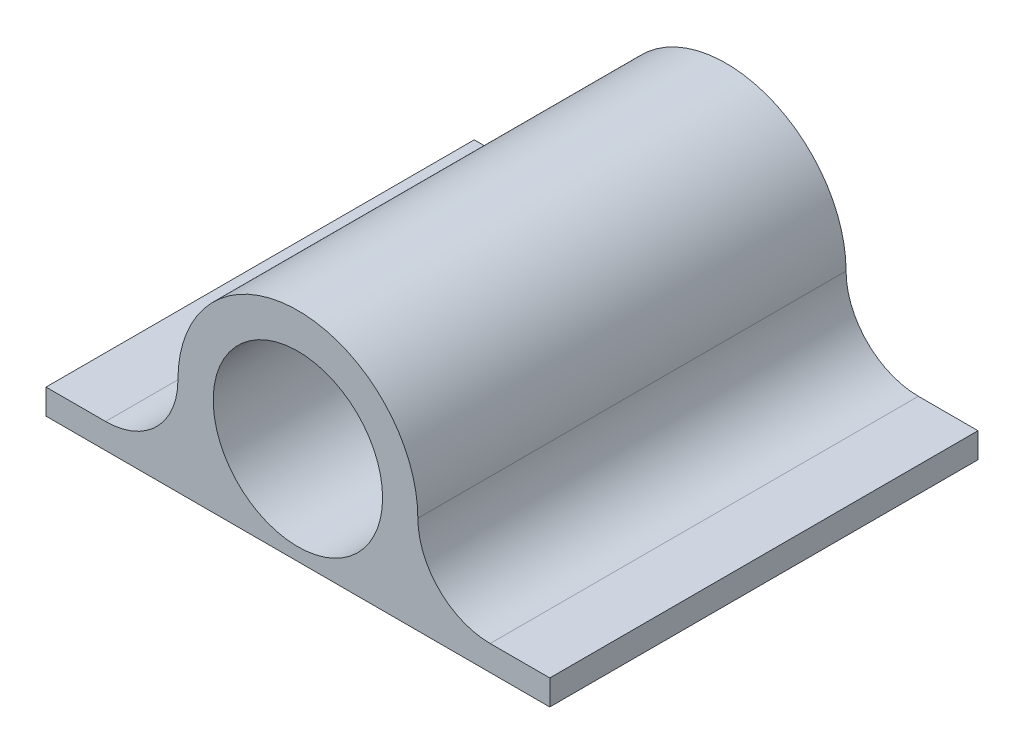
from build123d import *

# Parameters (mm, degrees)
SKETCH1_R           = 3.1115
BOSS_EXTRUDE1_DEPTH = 20.32
SKETCH2_R           = 1.905
BOSS_EXTRUDE2_DEPTH = 1.27
SKETCH3_R           = 4.27
CUT_EXTRUDE1_DEPTH  = 10.16


with BuildPart() as part:
    # Sketch1 → Boss-Extrude1 (new body)
    with BuildSketch(Plane.XY):
        with BuildLine():
            Line((-9.694539288, -3.646539288), (-12.7, -3.646539288))
            Line((-12.7, -3.646539288), (-12.7, -4.916539288))
            Line((-12.7, -4.916539288), (12.7, -4.916539288))
            Line((12.7, -4.916539288), (12.7, -3.646539288))
            Line((12.7, -3.646539288), (9.694539288, -3.646539288))
            ThreePointArc((9.694539288, -3.646539288), (7.11604663, -2.578492658), (6.048, 0))
            ThreePointArc((6.048, 0), (0, 6.048), (-6.048, 0))
            ThreePointArc((-6.048, 0), (-7.11604663, -2.578492658), (-9.694539288, -3.646539288))
        make_face()
        Circle(SKETCH1_R, mode=Mode.SUBTRACT)
    extrude(amount=BOSS_EXTRUDE1_DEPTH)

    # Sketch2 → Boss-Extrude2 (add)
    with BuildSketch(Plane(origin=(0, 0, 0), x_dir=(-1, 0, 0), z_dir=(0, 0, -1))):
        with BuildLine():
            Line((12.7, -4.916539288), (12.7, -3.646539288))
            Line((12.7, -3.646539288), (9.694539288, -3.646539288))
            ThreePointArc((9.694539288, -3.646539288), (7.11604663, -2.578492658), (6.048, 0))
            ThreePointArc((6.048, 0), (0, 6.048), (-6.048, 0))
            ThreePointArc((-6.048, 0), (-7.11604663, -2.578492658), (-9.694539288, -3.646539288))
            Line((-9.694539288, -3.646539288), (-12.7, -3.646539288))
            Line((-12.7, -3.646539288), (-12.7, -4.916539288))
            Line((-12.7, -4.916539288), (12.7, -4.916539288))
        make_face()
        Circle(SKETCH2_R, mode=Mode.SUBTRACT)
    extrude(amount=BOSS_EXTRUDE2_DEPTH)

    # Sketch3 → Cut-Extrude1 (cut)
    with BuildSketch(Plane.XY.offset(20.32)):
        Circle(SKETCH3_R)
    extrude(amount=-CUT_EXTRUDE1_DEPTH, mode=Mode.SUBTRACT)


solid = part.part
